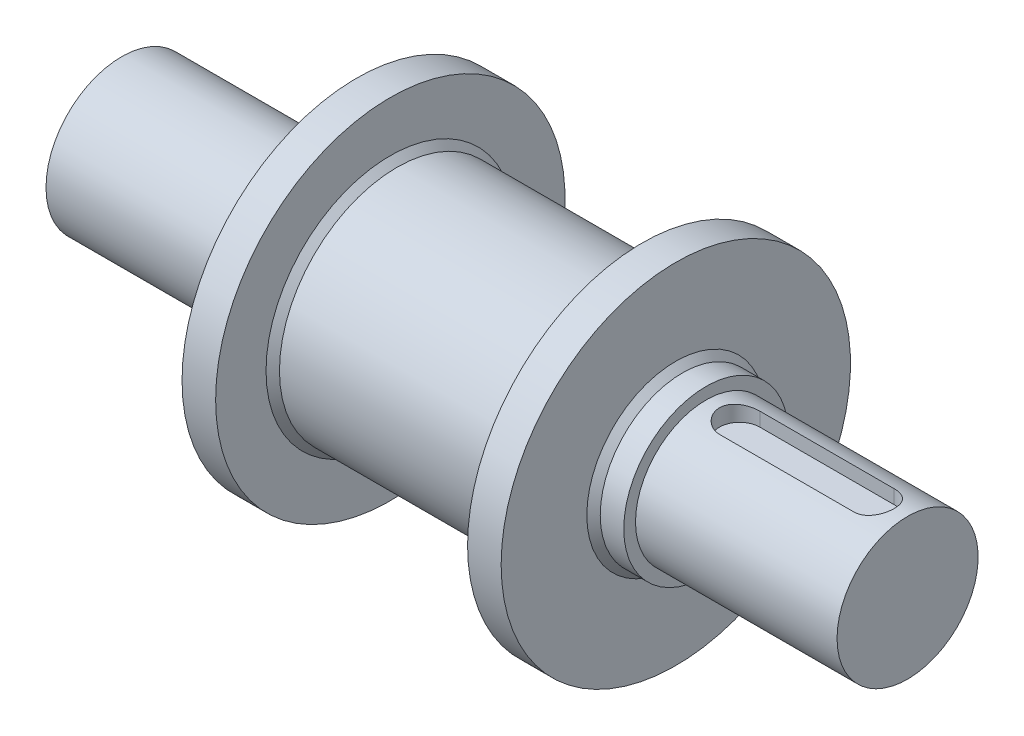
from build123d import *

# Parameters (mm, degrees)
CHAMFER1_SIZE      = 2
CUT_EXTRUDE1_DEPTH = 5


with BuildPart() as part:
    # Sketch1 → Revolve1 (revolve)
    with BuildSketch(Plane.XY):
        Polygon((0, 0), (0, 22.5), (65, 22.5), (65, 27), (70, 27), (70, 52), (80, 52), (80, 35), (155, 35), (155, 52), (165, 52), (165, 24.5), (174, 24.5), (174, 21), (234, 21), (234, 0), align=None)
    revolve(axis=Axis((0, 0, 0), (1, 0, 0)))

    # Chamfer1
    chamfer1_edges = [part.edges().sort_by_distance(p)[0] for p in [
        (165, -24.5, 0),
        (155, -35, 0),
        (80, -35, 0),
    ]]
    chamfer(chamfer1_edges, length=CHAMFER1_SIZE)

    # Sketch2 → Cut-Extrude1 (cut)
    with BuildSketch(Plane(origin=(0, 21, 0), x_dir=(1, 0, 0), z_dir=(0, 1, 0))):
        with BuildLine():
            Line((204, 6), (204, -6))
            Line((204, -6), (184, -6))
            ThreePointArc((184, -6), (178, 0), (184, 6))
            Line((184, 6), (204, 6))
        make_face()
    cut_extrude1 = extrude(amount=-CUT_EXTRUDE1_DEPTH, mode=Mode.SUBTRACT)

    # Mirror1: Cut-Extrude1 across plane
    add(cut_extrude1.mirror(Plane(origin=(204, 16, -6), x_dir=(0, 0, 1), z_dir=(1, 0, 0))), mode=Mode.SUBTRACT)


solid = part.part
